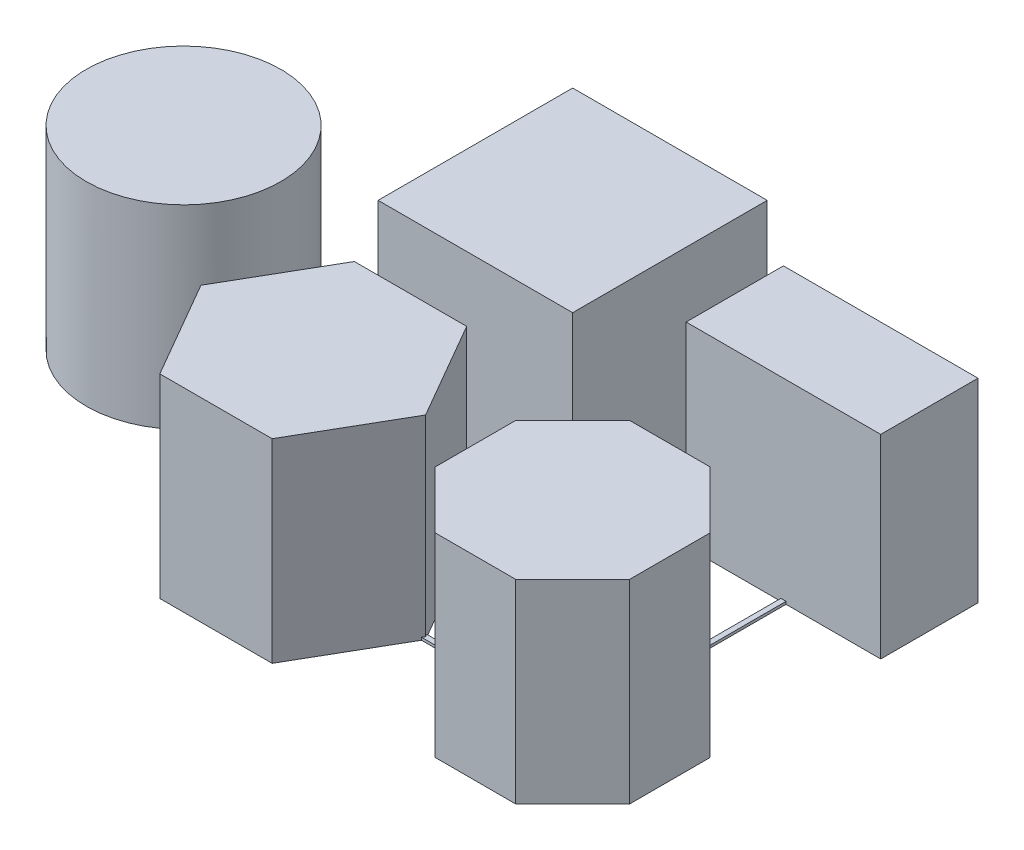
from build123d import *

# Parameters (mm, degrees)
SKIZZE1_R                         = 15
AUFSATZ_LINEAR_AUSTRAGEN1_DEPTH   = 30
SKIZZE1_W                         = 30
SKIZZE1_H                         = 30
AUFSATZ_LINEAR_AUSTRAGEN1_2_DEPTH = 30
AUFSATZ_LINEAR_AUSTRAGEN1_3_DEPTH = 30
SKIZZE1_H_2                       = 15
AUFSATZ_LINEAR_AUSTRAGEN1_4_DEPTH = 30
AUFSATZ_LINEAR_AUSTRAGEN1_5_DEPTH = 30
LINEAR_AUSTRAGEN_D_NN1_DEPTH      = 0.4


with BuildPart() as part:
    # Skizze1 → Aufsatz-Linear austragen1 (new body)
    with BuildSketch(Plane(origin=(0, 0, 0), x_dir=(1, 0, 0), z_dir=(0, 1, 0))):
        with Locations((-10, 0)):
            Circle(SKIZZE1_R)
    extrude(amount=AUFSATZ_LINEAR_AUSTRAGEN1_DEPTH)



with BuildPart() as body_2:
    # Skizze1 → Aufsatz-Linear austragen1 2 (new body)
    with BuildSketch(Plane(origin=(0, 0, 0), x_dir=(1, 0, 0), z_dir=(0, 1, 0))):
        with Locations((30, 20)):
            Rectangle(SKIZZE1_W, SKIZZE1_H)
    extrude(amount=AUFSATZ_LINEAR_AUSTRAGEN1_2_DEPTH)


with BuildPart() as body_3:
    # Skizze1 → Aufsatz-Linear austragen1 3 (new body)
    with BuildSketch(Plane(origin=(0, 0, 0), x_dir=(1, 0, 0), z_dir=(0, 1, 0))):
        Polygon((38.660254038, -5), (21.339745962, -5), (12.679491924, -20), (21.339745962, -35), (38.660254038, -35), (47.320508076, -20), align=None)
    extrude(amount=AUFSATZ_LINEAR_AUSTRAGEN1_3_DEPTH)


with BuildPart() as body_4:
    # Skizze1 → Aufsatz-Linear austragen1 4 (new body)
    with BuildSketch(Plane(origin=(0, 0, 0), x_dir=(1, 0, 0), z_dir=(0, 1, 0))):
        with Locations((70, 20)):
            Rectangle(SKIZZE1_W, SKIZZE1_H_2)
    extrude(amount=AUFSATZ_LINEAR_AUSTRAGEN1_4_DEPTH)


with BuildPart() as body_5:
    # Skizze1 → Aufsatz-Linear austragen1 5 (new body)
    with BuildSketch(Plane(origin=(0, 0, 0), x_dir=(1, 0, 0), z_dir=(0, 1, 0))):
        Polygon((76.213203436, -5), (63.786796564, -5), (55, -13.786796564), (55, -26.213203436), (63.786796564, -35), (76.213203436, -35), (85, -26.213203436), (85, -13.786796564), align=None)
    extrude(amount=AUFSATZ_LINEAR_AUSTRAGEN1_5_DEPTH)


with BuildPart() as part_1:
    add(part.part)

    add(body_2.part)  # Linear-Austragen-Dünn1 merges body 2

    add(body_3.part)  # Linear-Austragen-Dünn1 merges body 3

    add(body_4.part)  # Linear-Austragen-Dünn1 merges body 4

    add(body_5.part)  # Linear-Austragen-Dünn1 merges body 5
    # Skizze2 → Linear-Austragen-Dünn1 (add)
    with BuildSketch(Plane.XZ):
        Polygon((29.905572809, 20.4), (-10.894427191, 0), (29.905572809, -20.4), (70.4, -20.4), (70.4, 20.4), align=None)
        Polygon((30.094427191, 19.6), (-9.105572809, 0), (30.094427191, -19.6), (69.6, -19.6), (69.6, 19.6), align=None, mode=Mode.SUBTRACT)
    extrude(amount=-LINEAR_AUSTRAGEN_D_NN1_DEPTH)


solid = part_1.part
